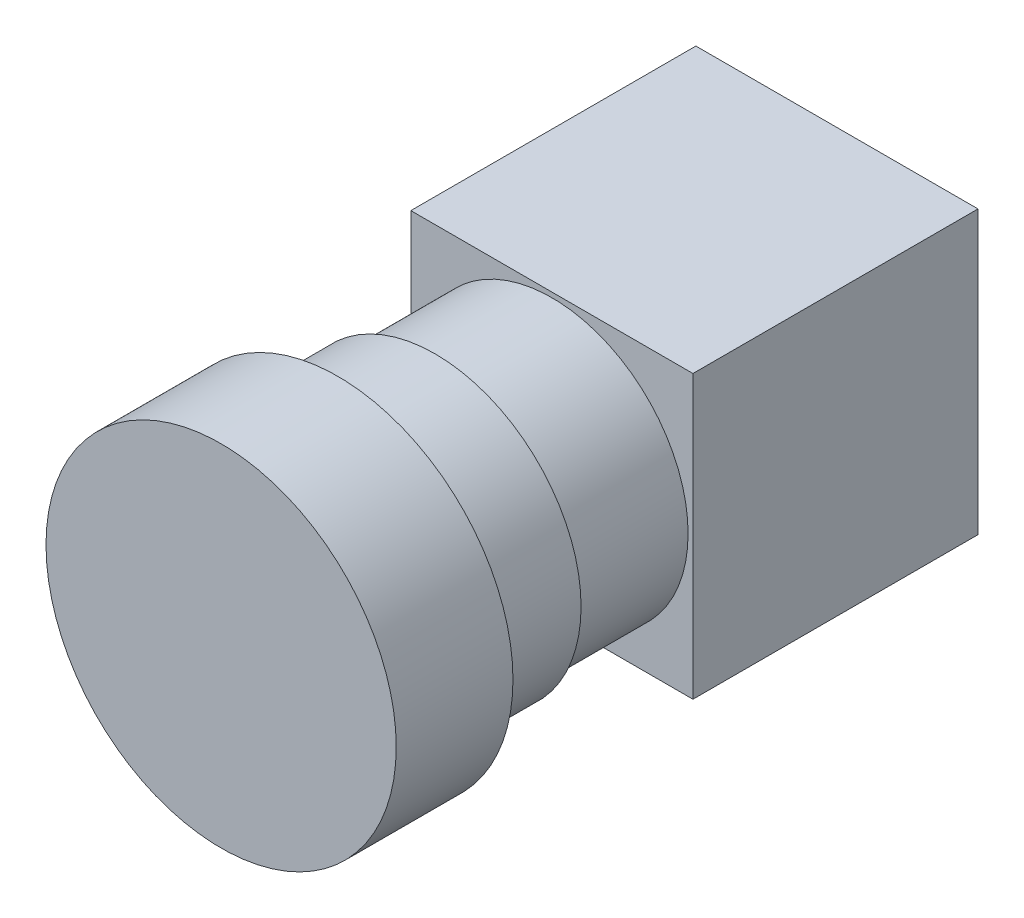
from build123d import *

# Parameters (mm, degrees)
SKETCH_3_W          = 29
SKETCH_3_H          = 29
EXTRUDE_2_DEPTH     = 29.3
SKETCH_4_R          = 14
EXTRUDE_3_DEPTH     = 12
SKETCH_5_R          = 15
EXTRUDE_4_DEPTH     = 10
SKETCH_6_R          = 18
EXTRUDE_5_DEPTH     = 12
CUT_EXTRUDE_1_DEPTH = 5


with BuildPart() as part:
    # 草图3 → 凸台-拉伸2 (new body)
    with BuildSketch(Plane.XY):
        Rectangle(SKETCH_3_W, SKETCH_3_H)
    extrude(amount=EXTRUDE_2_DEPTH)

    # 草图4 → 凸台-拉伸3 (add)
    with BuildSketch(Plane.XY.offset(29.3)):
        Circle(SKETCH_4_R)
    extrude(amount=EXTRUDE_3_DEPTH)

    # 草图5 → 凸台-拉伸4 (add)
    with BuildSketch(Plane.XY.offset(41.3)):
        Circle(SKETCH_5_R)
    extrude(amount=EXTRUDE_4_DEPTH)

    # 草图6 → 凸台-拉伸5 (add)
    with BuildSketch(Plane.XY.offset(51.3)):
        Circle(SKETCH_6_R)
    extrude(amount=EXTRUDE_5_DEPTH)

    # 草图7 → 切除-拉伸1 (cut)
    with BuildSketch(Plane.XZ.offset(14.5)):
        with BuildLine():
            Line((-9.85, 24.65), (-9.85, 26.15))
            Line((-9.85, 26.15), (-8.35, 26.15))
            ThreePointArc((-8.35, 26.15), (-10.910660172, 27.210660172), (-9.85, 24.65))
        make_face()
        with BuildLine():
            Line((-8.35, 26.15), (-9.85, 26.15))
            Line((-9.85, 26.15), (-9.85, 24.65))
            ThreePointArc((-9.85, 24.65), (-8.789339828, 25.089339828), (-8.35, 26.15))
        make_face()
        with BuildLine():
            ThreePointArc((11.35, 26.15), (9.85, 27.65), (8.35, 26.15))
            Line((8.35, 26.15), (9.85, 26.15))
            Line((9.85, 26.15), (9.85, 24.65))
            ThreePointArc((9.85, 24.65), (10.910660172, 25.089339828), (11.35, 26.15))
        make_face()
        with BuildLine():
            Line((9.85, 26.15), (8.35, 26.15))
            ThreePointArc((8.35, 26.15), (8.789339828, 25.089339828), (9.85, 24.65))
            Line((9.85, 24.65), (9.85, 26.15))
        make_face()
        with BuildLine():
            ThreePointArc((1.5, 3.15), (0, 4.65), (-1.5, 3.15))
            Line((-1.5, 3.15), (1.5, 3.15))
        make_face()
        with BuildLine():
            Line((1.5, 3.15), (-1.5, 3.15))
            ThreePointArc((-1.5, 3.15), (0, 1.65), (1.5, 3.15))
        make_face()
    extrude(amount=-CUT_EXTRUDE_1_DEPTH, mode=Mode.SUBTRACT)


solid = part.part
